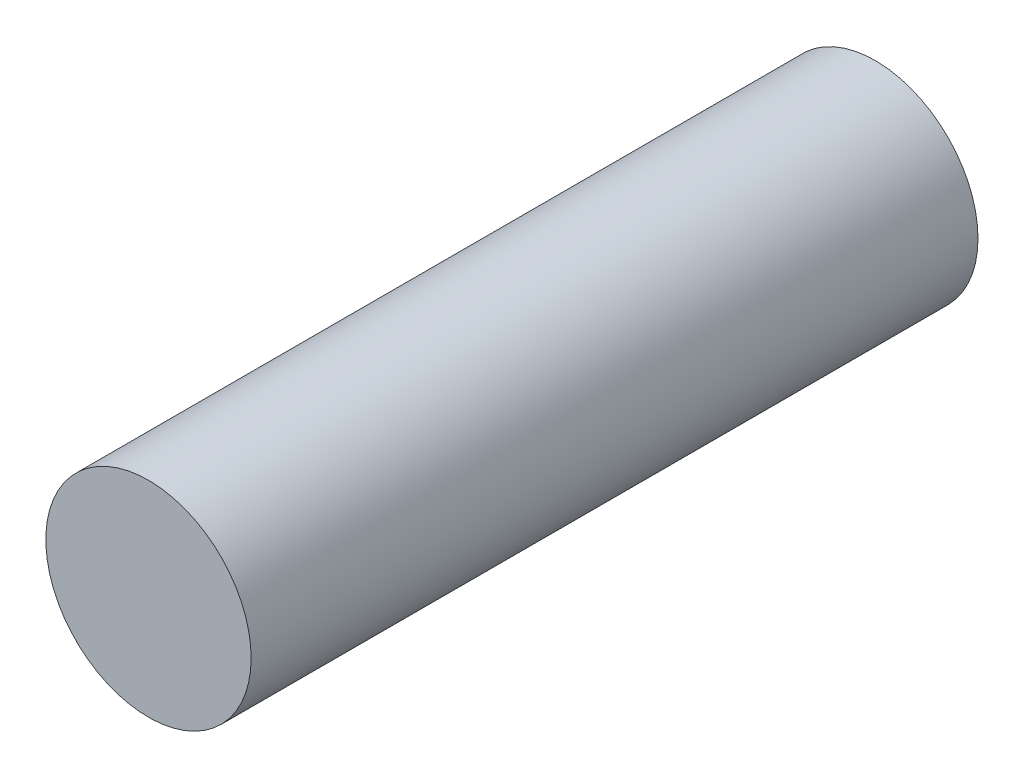
from build123d import *

# Parameters (mm, degrees)
SKETCH1_R           = 9.25
BOSS_EXTRUDE1_DEPTH = 65.5


with BuildPart() as part:
    # Sketch1 → Boss-Extrude1 (new body)
    with BuildSketch(Plane.XY):
        Circle(SKETCH1_R)
    extrude(amount=BOSS_EXTRUDE1_DEPTH)


solid = part.part
